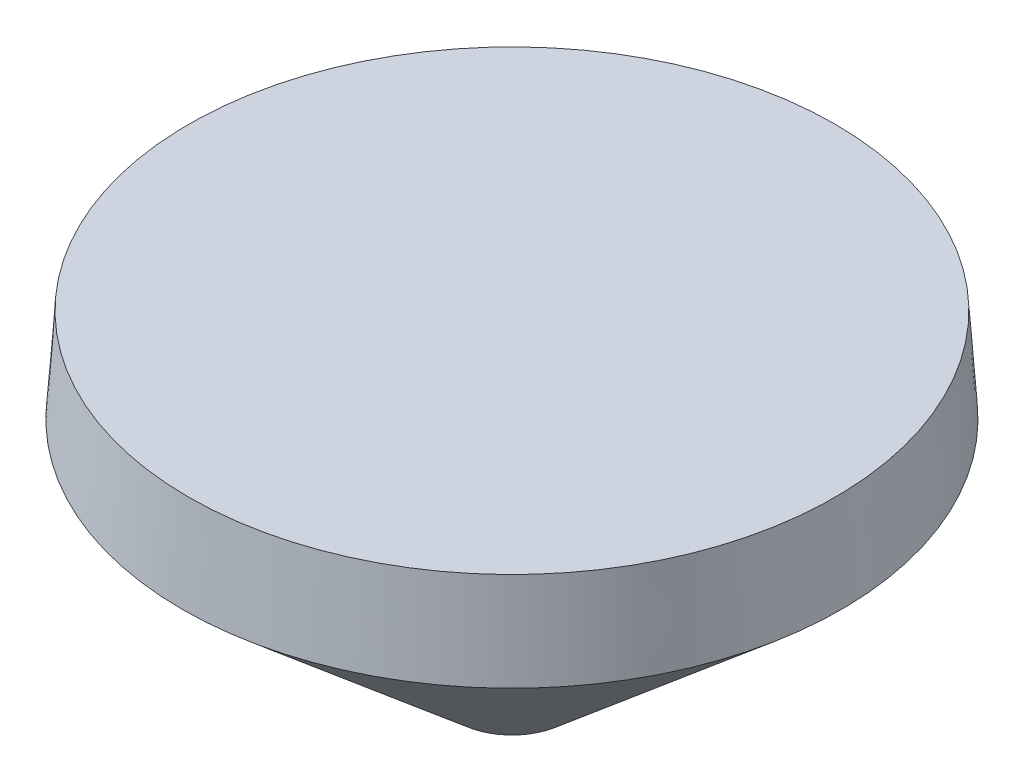
from build123d import *


with BuildPart() as part:
    # Croquis1 → Revolución1 (revolve)
    with BuildSketch(Plane.XY):
        Polygon((0, 42), (41.275, 42), (42.1, 30), (7, 0), (0, 0), align=None)
    revolve(axis=Axis((0, 59.390909091, 0), (0, -1, 0)))


solid = part.part
